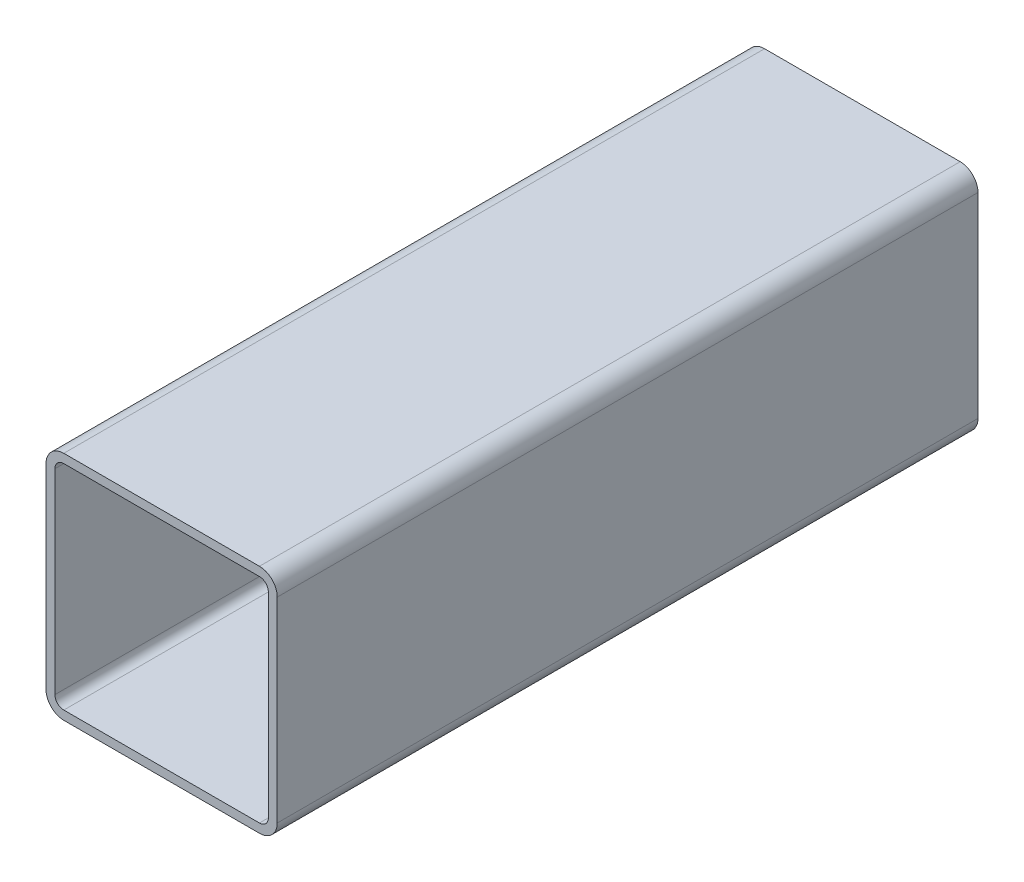
from build123d import *

# Parameters (mm, degrees)
EXTRUDE_THIN1_DEPTH = 10


with BuildPart() as part:
    # Sketch1 → Extrude-Thin1 (new body, symmetric)
    with BuildSketch(Plane.XY):
        with BuildLine():
            Line((2.792, 3.3), (-2.792, 3.3))
            ThreePointArc((-2.792, 3.3), (-3.151210245, 3.151210245), (-3.3, 2.792))
            Line((-3.3, 2.792), (-3.3, -2.792))
            ThreePointArc((-3.3, -2.792), (-3.151210245, -3.151210245), (-2.792, -3.3))
            Line((-2.792, -3.3), (2.792, -3.3))
            ThreePointArc((2.792, -3.3), (3.151210245, -3.151210245), (3.3, -2.792))
            Line((3.3, -2.792), (3.3, 2.792))
            ThreePointArc((3.3, 2.792), (3.151210245, 3.151210245), (2.792, 3.3))
        make_face()
        with BuildLine():
            Line((2.792, 3.046), (-2.792, 3.046))
            ThreePointArc((-2.792, 3.046), (-2.971605122, 2.971605122), (-3.046, 2.792))
            Line((-3.046, 2.792), (-3.046, -2.792))
            ThreePointArc((-3.046, -2.792), (-2.971605122, -2.971605122), (-2.792, -3.046))
            Line((-2.792, -3.046), (2.792, -3.046))
            ThreePointArc((2.792, -3.046), (2.971605122, -2.971605122), (3.046, -2.792))
            Line((3.046, -2.792), (3.046, 2.792))
            ThreePointArc((3.046, 2.792), (2.971605122, 2.971605122), (2.792, 3.046))
        make_face(mode=Mode.SUBTRACT)
    extrude(amount=EXTRUDE_THIN1_DEPTH, both=True)


solid = part.part
